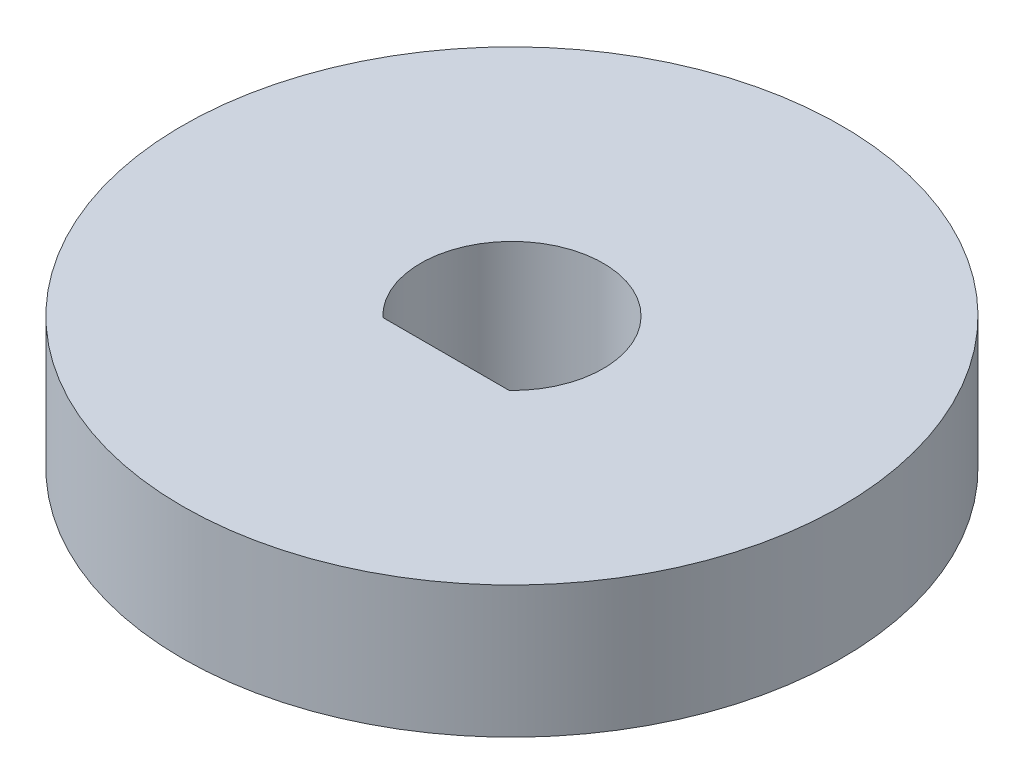
from build123d import *

# Parameters (mm, degrees)
SKETCH1_R           = 10
BOSS_EXTRUDE1_DEPTH = 4


with BuildPart() as part:
    # Sketch1 → Boss-Extrude1 (new body)
    with BuildSketch(Plane(origin=(0, 0, 0), x_dir=(1, 0, 0), z_dir=(0, 1, 0))):
        Circle(SKETCH1_R)
        with BuildLine():
            Line((-1.918332609, -2), (1.918332609, -2))
            ThreePointArc((1.918332609, -2), (0, 2.771281292), (-1.918332609, -2))
        make_face(mode=Mode.SUBTRACT)
    extrude(amount=BOSS_EXTRUDE1_DEPTH)


solid = part.part
